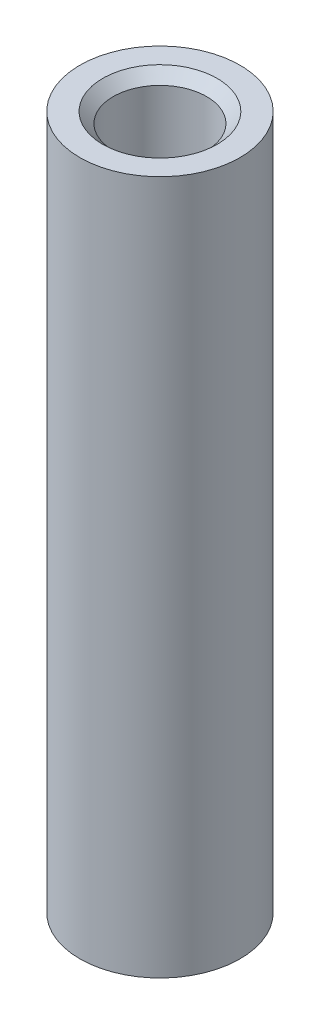
from build123d import *

# Parameters (mm, degrees)
SKETCH1_R           = 38.1
SKETCH1_R_2         = 22.225
BOSS_EXTRUDE1_DEPTH = 330.2
CHAMFER2_SIZE       = 5


with BuildPart() as part:
    # Sketch1 → Boss-Extrude1 (new body)
    with BuildSketch(Plane(origin=(0, 0, 0), x_dir=(1, 0, 0), z_dir=(0, 1, 0))):
        Circle(SKETCH1_R)
        Circle(SKETCH1_R_2, mode=Mode.SUBTRACT)
    extrude(amount=BOSS_EXTRUDE1_DEPTH)

    # Chamfer2
    chamfer2_edges = [part.edges().sort_by_distance(p)[0] for p in [
        (-22.225, 330.2, 0),
    ]]
    chamfer(chamfer2_edges, length=CHAMFER2_SIZE)


solid = part.part
